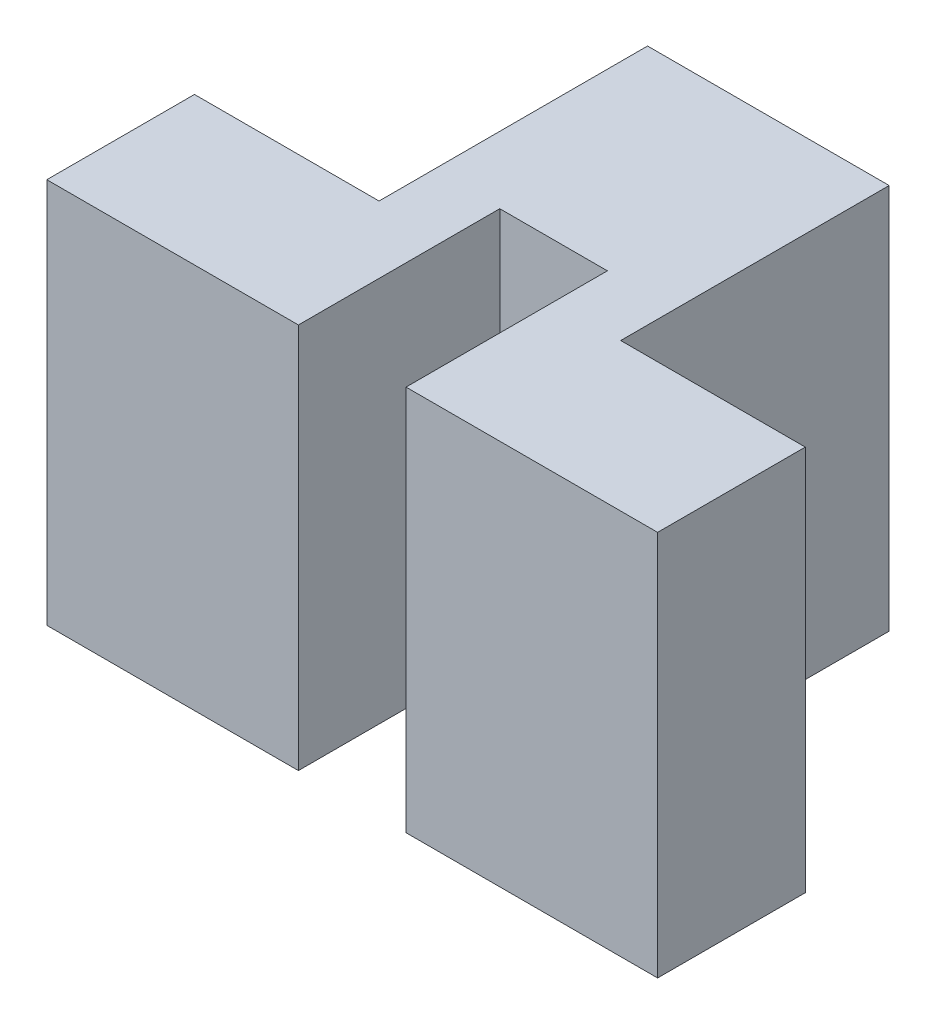
from build123d import *

# Parameters (mm, degrees)
SKETCH1_W           = 9.1
SKETCH1_H           = 5.75
BOSS_EXTRUDE1_DEPTH = 2.2
SKETCH3_W           = 3.6
SKETCH3_H           = 5.75
BOSS_EXTRUDE2_DEPTH = 4
SKETCH2_W           = 1.60331862
SKETCH2_H           = 15
CUT_EXTRUDE1_DEPTH  = 3


with BuildPart() as part:
    # Sketch1 → Boss-Extrude1 (new body)
    with BuildSketch(Plane.XY):
        with Locations((-13.05, 11.375)):
            Rectangle(SKETCH1_W, SKETCH1_H)
    extrude(amount=BOSS_EXTRUDE1_DEPTH)

    # Sketch3 → Boss-Extrude2 (add)
    with BuildSketch(Plane(origin=(0, 0, 0), x_dir=(-1, 0, 0), z_dir=(0, 0, -1))):
        with Locations((13.05, 11.375)):
            Rectangle(SKETCH3_W, SKETCH3_H)
    extrude(amount=BOSS_EXTRUDE2_DEPTH)

    # Sketch2 → Cut-Extrude1 (cut)
    with BuildSketch(Plane.XY.offset(2.2)):
        with Locations((-13.05, 11.375)):
            Rectangle(SKETCH2_W, SKETCH2_H)
    extrude(amount=-CUT_EXTRUDE1_DEPTH, mode=Mode.SUBTRACT)


solid = part.part
